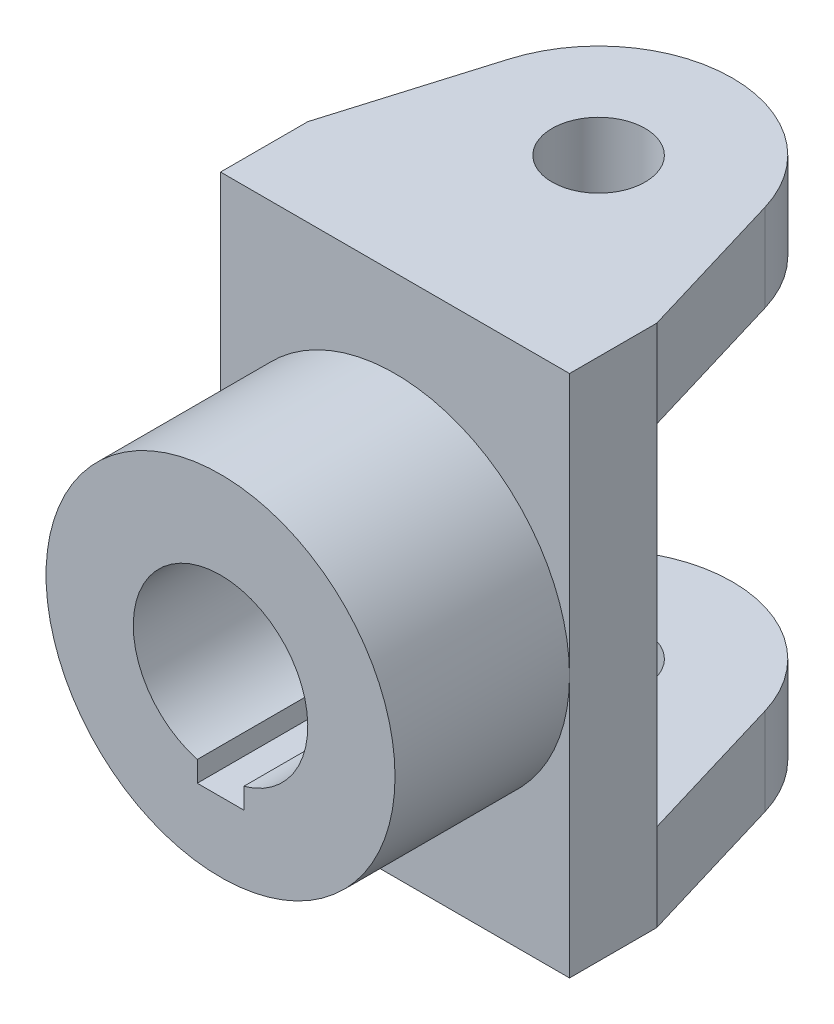
from build123d import *

# Parameters (mm, degrees)
SKETCH1_W           = 60
SKETCH1_H           = 90
BOSS_EXTRUDE1_DEPTH = 7.5
SKETCH2_R           = 30
BOSS_EXTRUDE4_DEPTH = 30
SKETCH3_R           = 8
BOSS_EXTRUDE5_DEPTH = 15


with BuildPart() as part:
    # Sketch1 → Boss-Extrude1 (new body, symmetric)
    with BuildSketch(Plane.XY):
        Rectangle(SKETCH1_W, SKETCH1_H)
    extrude(amount=BOSS_EXTRUDE1_DEPTH, both=True)

    # Sketch2 → Boss-Extrude4 (add)
    with BuildSketch(Plane.XY.offset(7.5)):
        Circle(SKETCH2_R)
        with BuildLine():
            Line((4, -18), (0, -18))
            Line((0, -18), (-4, -18))
            Line((-4, -18), (-4, -15))
            Line((-4, -15), (-4, -14.456832295))
            ThreePointArc((-4, -14.456832295), (-9.082951062, 11.937336386), (15, 0))
            ThreePointArc((15, 0), (11.937336386, -9.082951062), (4, -14.456832295))
            Line((4, -14.456832295), (4, -18))
        make_face(mode=Mode.SUBTRACT)
    extrude(amount=BOSS_EXTRUDE4_DEPTH)

    # Sketch3 → Boss-Extrude5 (add)
    with BuildSketch(Plane(origin=(0, 45, 0), x_dir=(1, 0, 0), z_dir=(0, 1, 0))):
        with BuildLine():
            Line((-22.03289839, 34.099347585), (-30, 7.5))
            Line((-30, 7.5), (-11.357816691, 7.5))
            ThreePointArc((-11.357816691, 7.5), (-21.345170095, 18.933570545), (-22.03289839, 34.099347585))
        make_face()
        with BuildLine():
            Line((30, 7.5), (22.03289839, 34.099347585))
            ThreePointArc((22.03289839, 34.099347585), (22.756940293, 30.834916568), (23, 27.5))
            ThreePointArc((23, 27.5), (19.877497125, 15.929126738), (11.357816692, 7.5))
            Line((11.357816692, 7.5), (30, 7.5))
        make_face()
        with BuildLine():
            ThreePointArc((22.03289839, 34.099347585), (0, 50.5), (-22.03289839, 34.099347585))
            ThreePointArc((-22.03289839, 34.099347585), (-21.345170095, 18.933570545), (-11.357816691, 7.5))
            Line((-11.357816691, 7.5), (11.357816692, 7.5))
            ThreePointArc((11.357816692, 7.5), (19.877497125, 15.929126738), (23, 27.5))
            ThreePointArc((23, 27.5), (22.756940293, 30.834916568), (22.03289839, 34.099347585))
        make_face()
        with Locations((0, 27.5)):
            Circle(SKETCH3_R, mode=Mode.SUBTRACT)
    boss_extrude5 = extrude(amount=-BOSS_EXTRUDE5_DEPTH)

    # Mirror1: Boss-Extrude5 across plane
    add(boss_extrude5.mirror(Plane.ZX))


solid = part.part
